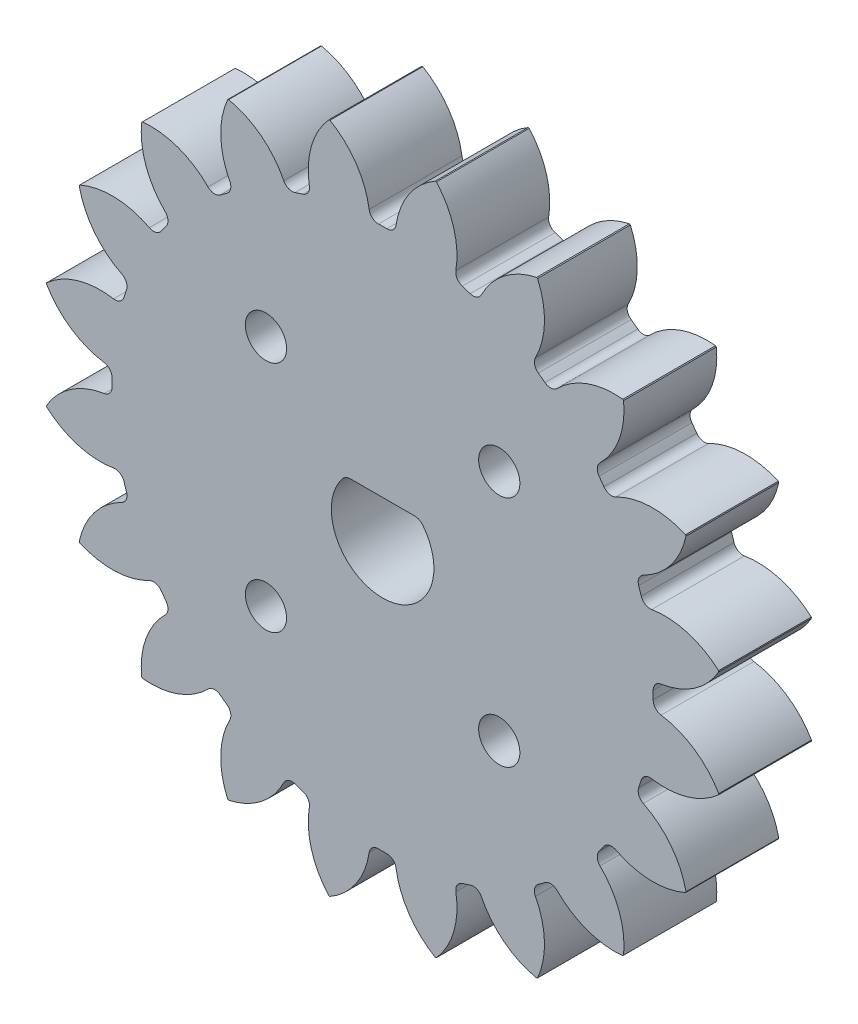
from build123d import *

# Parameters (mm, degrees)
SKETCH1_R                = 33
BOSS_EXTRUDE1_DEPTH      = 9
CUT_EXTRUDE1_START       = -10
CUT_EXTRUDE1_DEPTH       = 11
FILLET1_R                = 0.9
CIRPATTERN3_COUNT        = 20
FILLET1_OF_CIRPATTERN3_R = 0.9
CUT_EXTRUDE3_DEPTH       = 10.0000001
FILLET2_R                = 1
FILLET3_R                = 1
SKETCH4_R                = 2
CUT_EXTRUDE4_DEPTH       = 10.0000001


with BuildPart() as part:
    # Sketch1 → Boss-Extrude1 (new body)
    with BuildSketch(Plane.XY):
        Circle(SKETCH1_R)
    extrude(amount=BOSS_EXTRUDE1_DEPTH)

    # Sketch2 → Cut-Extrude1 (cut)
    with BuildSketch(Plane.XY.offset(9).offset(CUT_EXTRUDE1_START)):
        with BuildLine():
            Line((-145.149685153, 113.520243779), (-5.110395214, 32.60189965))
            ThreePointArc((-5.110395214, 32.60189965), (-2.353772872, 29.907520012), (-1.226544733, 26.221328876))
            ThreePointArc((-1.226544733, 26.221328876), (0, 26.25), (1.226544733, 26.221328876))
            ThreePointArc((1.226544733, 26.221328876), (2.353772872, 29.907520012), (5.110395214, 32.60189965))
            Line((5.110395214, 32.60189965), (145.149685153, 113.520243779))
            Line((145.149685153, 113.520243779), (145.149685153, 436.993773722))
            Line((145.149685153, 436.993773722), (-145.149685153, 436.993773722))
            Line((-145.149685153, 436.993773722), (-145.149685153, 113.520243779))
        make_face()
    cut_extrude1 = extrude(amount=CUT_EXTRUDE1_DEPTH, mode=Mode.SUBTRACT)

    # Fillet1
    fillet1_edges = [part.edges().sort_by_distance(p)[0] for p in [
        (1.226544733, 26.221328876, 4.5),
        (-1.226544733, 26.221328876, 4.5),
    ]]
    fillet(fillet1_edges, radius=FILLET1_R)

    # CirPattern3: Cut-Extrude1 ×20 about axis
    cirpattern3_axis = Axis((0, 0, 0), (0, 0, 1))
    for i in range(1, CIRPATTERN3_COUNT):
        add(cut_extrude1.rotate(cirpattern3_axis, i * 360 / CIRPATTERN3_COUNT), mode=Mode.SUBTRACT)

    # Fillet1 of CirPattern3
    fillet1_of_cirpattern3_edges = [part.edges().sort_by_distance(p)[0] for p in [
        (-6.936322876, 25.31698886, 4.5),
        (-9.269349599, 24.558942526, 4.5),
        (-14.420214875, 21.934445581, 4.5),
        (-16.404805943, 20.49255577, 4.5),
        (-20.49255577, 16.404805943, 4.5),
        (-21.934445581, 14.420214875, 4.5),
        (-24.558942526, 9.269349599, 4.5),
        (-25.31698886, 6.936322876, 4.5),
        (-26.221328876, 1.226544733, 4.5),
        (-26.221328876, -1.226544733, 4.5),
        (-25.31698886, -6.936322876, 4.5),
        (-24.558942526, -9.269349599, 4.5),
        (-21.934445581, -14.420214875, 4.5),
        (-20.49255577, -16.404805943, 4.5),
        (-16.404805943, -20.49255577, 4.5),
        (-14.420214875, -21.934445581, 4.5),
        (-9.269349599, -24.558942526, 4.5),
        (-6.936322876, -25.31698886, 4.5),
        (-1.226544733, -26.221328876, 4.5),
        (1.226544733, -26.221328876, 4.5),
        (6.936322876, -25.31698886, 4.5),
        (9.269349599, -24.558942526, 4.5),
        (14.420214875, -21.934445581, 4.5),
        (16.404805943, -20.49255577, 4.5),
        (20.49255577, -16.404805943, 4.5),
        (21.934445581, -14.420214875, 4.5),
        (24.558942526, -9.269349599, 4.5),
        (25.31698886, -6.936322876, 4.5),
        (26.221328876, -1.226544733, 4.5),
        (26.221328876, 1.226544733, 4.5),
        (25.31698886, 6.936322876, 4.5),
        (24.558942526, 9.269349599, 4.5),
        (21.934445581, 14.420214875, 4.5),
        (20.49255577, 16.404805943, 4.5),
        (16.404805943, 20.49255577, 4.5),
        (14.420214875, 21.934445581, 4.5),
        (9.269349599, 24.558942526, 4.5),
        (6.936322876, 25.31698886, 4.5),
    ]]
    fillet(fillet1_of_cirpattern3_edges, radius=FILLET1_OF_CIRPATTERN3_R)

    # Sketch3 → Cut-Extrude3 (cut, through all)
    with BuildSketch(Plane.XY.offset(9)):
        with BuildLine():
            Line((3.560196624, 3.475), (-3.560196624, 3.475))
            ThreePointArc((-3.560196624, 3.475), (-1.87598598, -4.607743656), (4.975, 0))
            ThreePointArc((4.975, 0), (4.607743656, 1.87598598), (3.560196624, 3.475))
        make_face()
    extrude(amount=-CUT_EXTRUDE3_DEPTH, mode=Mode.SUBTRACT)

    # Fillet2
    fillet2_edges = [part.edges().sort_by_distance(p)[0] for p in [
        (-3.560196624, 3.475, 4.5),
    ]]
    fillet(fillet2_edges, radius=FILLET2_R)

    # Fillet3
    fillet3_edges = [part.edges().sort_by_distance(p)[0] for p in [
        (3.560196624, 3.475, 4.5),
    ]]
    fillet(fillet3_edges, radius=FILLET3_R)

    # Sketch4 → Cut-Extrude4 (cut, through all)
    with BuildSketch(Plane.XY.offset(9)):
        with Locations((-11.313708499, 11.313708499)):
            Circle(SKETCH4_R)
        with Locations((11.313708499, 11.313708499)):
            Circle(SKETCH4_R)
        with Locations((11.313708499, -11.313708499)):
            Circle(SKETCH4_R)
        with Locations((-11.313708499, -11.313708499)):
            Circle(SKETCH4_R)
    extrude(amount=-CUT_EXTRUDE4_DEPTH, mode=Mode.SUBTRACT)


solid = part.part
